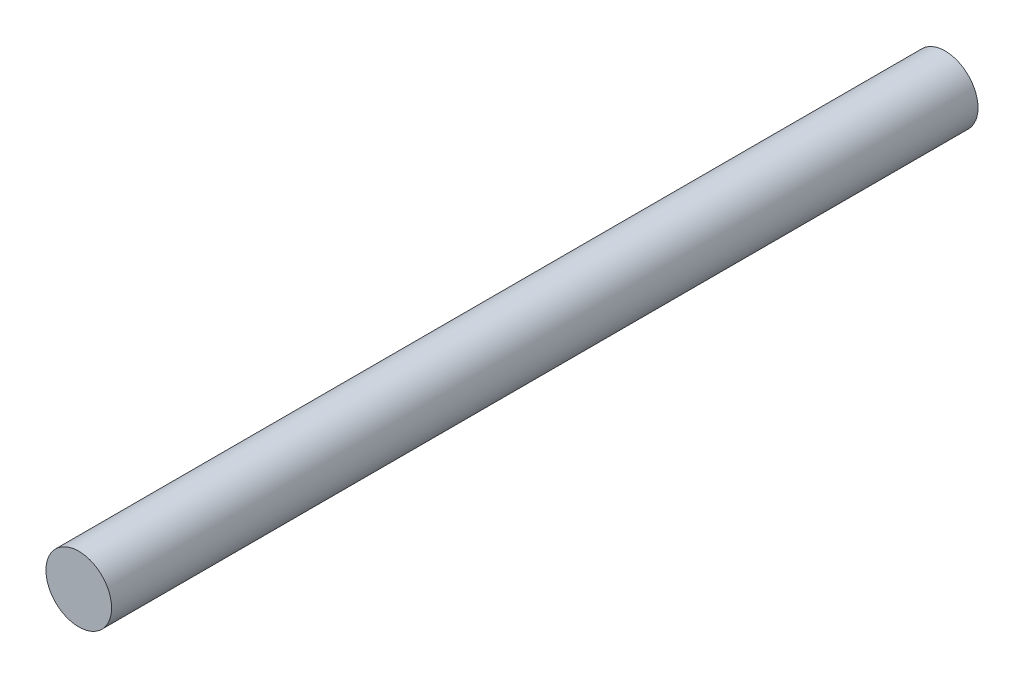
from build123d import *

# Parameters (mm, degrees)
CROQUIS1_R              = 2.5
SALIENTE_EXTRUIR1_DEPTH = 66


with BuildPart() as part:
    # Croquis1 → Saliente-Extruir1 (new body)
    with BuildSketch(Plane.XY):
        Circle(CROQUIS1_R)
    extrude(amount=SALIENTE_EXTRUIR1_DEPTH)


solid = part.part
